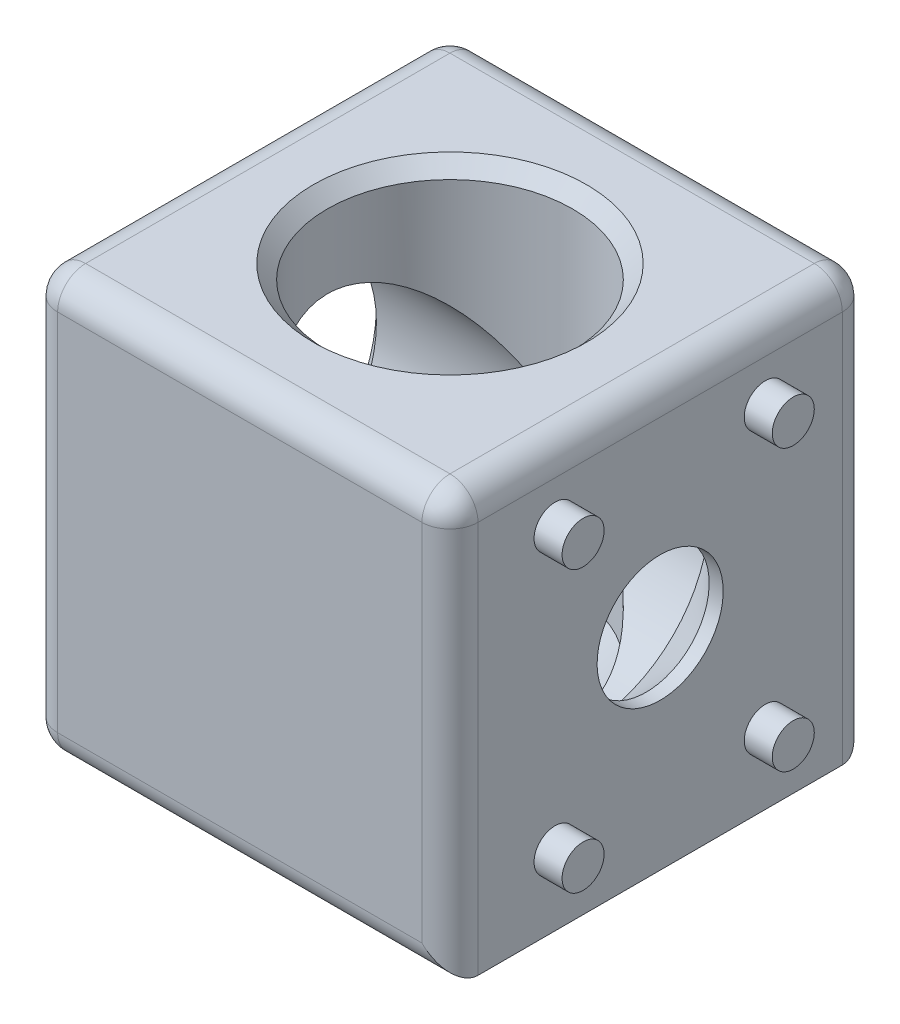
from build123d import *

# Parameters (mm, degrees)
SKETCH_1_W      = 30
SKETCH_1_H      = 30
EXTRUDE_1_DEPTH = 15
SKETCH_5_R      = 1.5
EXTRUDE_2_DEPTH = 2
FILLET_1_R      = 2


with BuildPart() as part:
    # Эскиз1 → Бобышка-Вытянуть1 (new body, symmetric)
    with BuildSketch(Plane(origin=(0, 0, 0), x_dir=(1, 0, 0), z_dir=(0, 1, 0))):
        Rectangle(SKETCH_1_W, SKETCH_1_H)
    extrude(amount=EXTRUDE_1_DEPTH, both=True)

    # Эскиз4 → Вырез-Повернуть1 (revolve, cut)
    with BuildSketch(Plane.XY):
        Polygon((-4.5, -15), (-4.5, -14), (-8.75, -9.75), (-8.75, 14), (-9.75, 15), (0, 15), (0, -15), align=None)
    cut_revolve_1 = revolve(axis=Axis((0, 15, 0), (0, -1, 0)), mode=Mode.SUBTRACT)

    # Эскиз5 → Бобышка-Вытянуть2 (add)
    with BuildSketch(Plane.XZ.offset(15)):
        with Locations(Location((-10, 7.5, 0), (0, 0, 270))):  # turned: the seam where the file's is
            Circle(SKETCH_5_R)
        with Locations(Location((-10, -7.5, 0), (0, 0, 270))):  # turned: the seam where the file's is
            Circle(SKETCH_5_R)
        with Locations(Location((10, -7.5, 0), (0, 0, 270))):  # turned: the seam where the file's is
            Circle(SKETCH_5_R)
        with Locations(Location((10, 7.5, 0), (0, 0, 270))):  # turned: the seam where the file's is
            Circle(SKETCH_5_R)
    extrude_2 = extrude(amount=EXTRUDE_2_DEPTH)

    # Зеркальное отражение1: Вырез-Повернуть1, Бобышка-Вытянуть2 across plane
    add(cut_revolve_1.mirror(Plane(origin=(0, 0, 0), x_dir=(0, 0, 1), z_dir=(0.707106781, 0.707106781, 0))), mode=Mode.SUBTRACT)
    add(extrude_2.mirror(Plane(origin=(0, 0, 0), x_dir=(0, 0, 1), z_dir=(0.707106781, 0.707106781, 0))))

    # Скругление1
    fillet_1_edges = [part.edges().sort_by_distance(p)[0] for p in [
        (-15, 15, 0),
        (0, 15, 15),
        (15, 15, 0),
        (0, -15, 15),
        (-15, -15, 0),
        (0, -15, -15),
        (15, 0, 15),
        (-15, 0, 15),
        (-15, 0, -15),
        (15, 0, -15),
        (0, 15, -15),
    ]]
    fillet(fillet_1_edges, radius=FILLET_1_R)


solid = part.part
